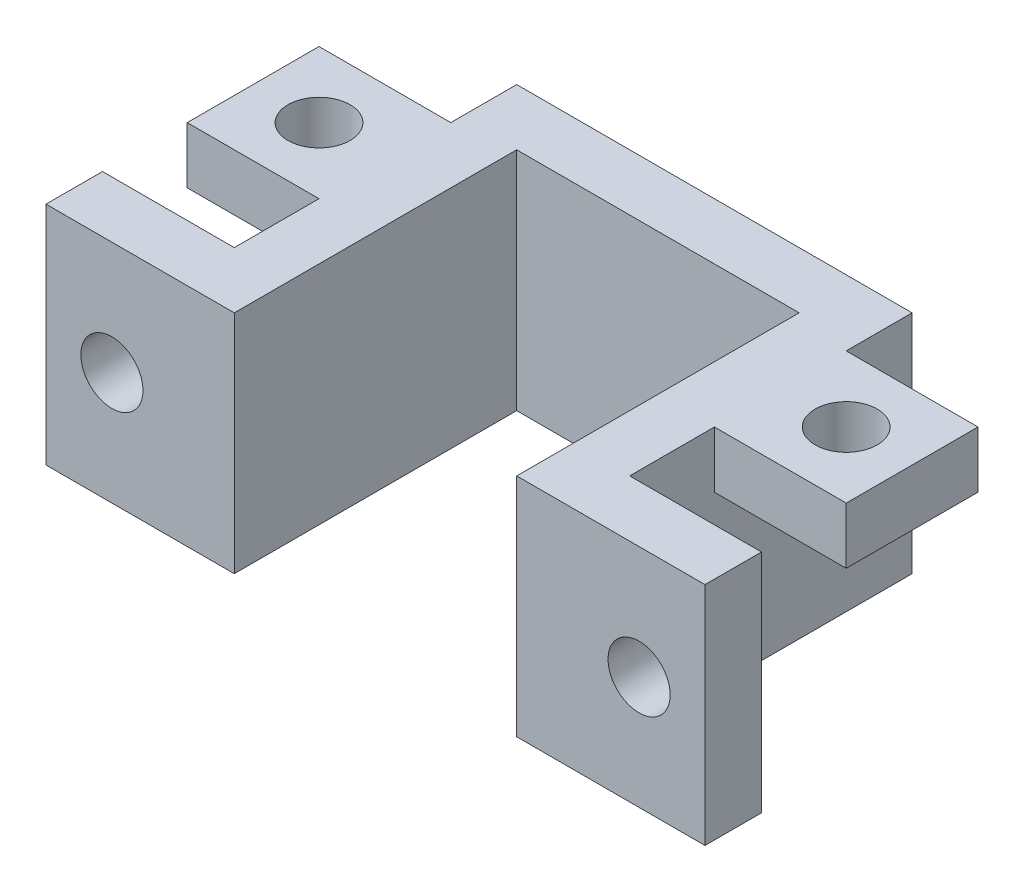
from build123d import *

# Parameters (mm, degrees)
BOSS_EXTRUDE1_DEPTH = 12
SKETCH2_R           = 1.65
CUT_EXTRUDE1_DEPTH  = 12
SKETCH3_W           = 7
SKETCH3_H           = 7
SKETCH3_R           = 1.65
BOSS_EXTRUDE2_DEPTH = 3


with BuildPart() as part:
    # Sketch1 → Boss-Extrude1 (new body)
    with BuildSketch(Plane(origin=(0, 0, 0), x_dir=(1, 0, 0), z_dir=(0, 1, 0))):
        Polygon((7.5, -7.5), (7.5, 7.5), (-7.5, 7.5), (-7.5, -7.5), (-17.5, -7.5), (-17.5, -4.5), (-10.5, -4.5), (-10.5, 10.5), (10.5, 10.5), (10.5, -4.5), (17.5, -4.5), (17.5, -7.5), align=None)
    extrude(amount=BOSS_EXTRUDE1_DEPTH)

    # Sketch2 → Cut-Extrude1 (cut)
    with BuildSketch(Plane.XY.offset(7.5)):
        with Locations((-14, 6)):
            Circle(SKETCH2_R)
        with Locations((14, 6)):
            Circle(SKETCH2_R)
    extrude(amount=-CUT_EXTRUDE1_DEPTH, mode=Mode.SUBTRACT)

    # Sketch3 → Boss-Extrude2 (add)
    with BuildSketch(Plane(origin=(0, 12, 0), x_dir=(1, 0, 0), z_dir=(0, 1, 0))):
        with Locations((-14, 3.5)):
            Rectangle(SKETCH3_W, SKETCH3_H)
        with Locations((-14, 3.5)):
            Circle(SKETCH3_R, mode=Mode.SUBTRACT)
        with Locations((14, 3.5)):
            Rectangle(SKETCH3_W, SKETCH3_H)
        with Locations((14, 3.5)):
            Circle(SKETCH3_R, mode=Mode.SUBTRACT)
    extrude(amount=-BOSS_EXTRUDE2_DEPTH)


solid = part.part
